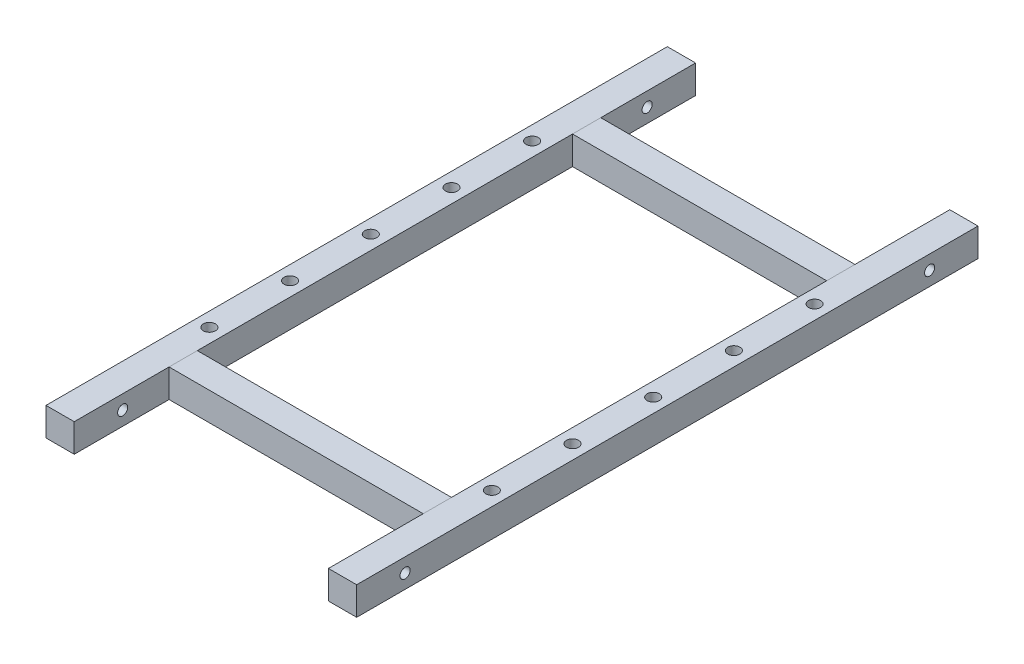
from build123d import *

# Parameters (mm, degrees)
SKETCH_14_W                   = 7
SKETCH_14_H                   = 7
BAR_7X7_1_DEPTH               = 154
SKETCH_14_ON_SEGMENT_2_W      = 7
SKETCH_14_ON_SEGMENT_2_H      = 7
BAR_7X7_1_2_DEPTH             = 154
SKETCH_14_ON_SEGMENT_3_W      = 7
SKETCH_14_ON_SEGMENT_3_H      = 7
BAR_7X7_1_3_DEPTH             = 72
SKETCH_14_ON_SEGMENT_4_W      = 7
SKETCH_14_ON_SEGMENT_4_H      = 7
BAR_7X7_1_4_DEPTH             = 72
SKETCH_12_R                   = 1.25
CUT_EXTRUDE_1_DEPTH           = 128.848543206
SKETCH_16_W                   = 1.5
SKETCH_16_H                   = 7
MM_TRANSITIONAL_1_AT_2_COUNT  = 2
MM_TRANSITIONAL_1_AT_2_PITCH  = 20
MM_TRANSITIONAL_1_AT_3_COUNT  = 2
MM_TRANSITIONAL_1_AT_3_PITCH  = 40
MM_TRANSITIONAL_1_AT_4_COUNT  = 2
MM_TRANSITIONAL_1_AT_4_PITCH  = 40
MM_TRANSITIONAL_1_AT_5_COUNT  = 2
MM_TRANSITIONAL_1_AT_5_PITCH  = 20
MM_TRANSITIONAL_1_AT_6_COUNT  = 2
MM_TRANSITIONAL_1_AT_6_PITCH  = 72.801098893
MM_TRANSITIONAL_1_AT_7_COUNT  = 2
MM_TRANSITIONAL_1_AT_7_PITCH  = 80.622577483
MM_TRANSITIONAL_1_AT_8_COUNT  = 2
MM_TRANSITIONAL_1_AT_8_PITCH  = 80.622577483
MM_TRANSITIONAL_1_AT_9_COUNT  = 2
MM_TRANSITIONAL_1_AT_9_PITCH  = 72.801098893
MM_TRANSITIONAL_1_AT_10_COUNT = 2
MM_TRANSITIONAL_1_AT_10_PITCH = 70


with BuildPart() as part:
    # 草图14 → Bar 7X7(1) (new body)
    with BuildSketch(Plane(origin=(-35, 0, -77), x_dir=(1, 0, 0), z_dir=(0, 0, 1))):
        Rectangle(SKETCH_14_W, SKETCH_14_H)
    extrude(amount=BAR_7X7_1_DEPTH)


with BuildPart() as body_2:
    # 草图14 on segment 2 (carried to segment 2) → Bar 7X7_1 2 (new body)
    with BuildSketch(Plane(origin=(35, 0, -77), x_dir=(1, 0, 0), z_dir=(0, 0, 1))):
        Rectangle(SKETCH_14_ON_SEGMENT_2_W, SKETCH_14_ON_SEGMENT_2_H)
    extrude(amount=BAR_7X7_1_2_DEPTH)


with BuildPart() as body_3:
    # 草图14 on segment 3 (carried to segment 3) → Bar 7X7_1 3 (new body)
    with BuildSketch(Plane(origin=(-36, 0, -50), x_dir=(0, 0, -1), z_dir=(1, 0, 0))):
        Rectangle(SKETCH_14_ON_SEGMENT_3_W, SKETCH_14_ON_SEGMENT_3_H)
    extrude(amount=BAR_7X7_1_3_DEPTH)

    # Bar 7X7_1 3 end butt 1
    split(bisect_by=Plane(origin=(-31.5, 0, -50), x_dir=(0, 1, 0), z_dir=(1, 0, 0)), keep=Keep.TOP)

    # Bar 7X7_1 3 end butt 2
    split(bisect_by=Plane(origin=(31.5, 0, -50), x_dir=(0, -1, 0), z_dir=(-1, 0, 0)), keep=Keep.TOP)


with BuildPart() as body_4:
    # 草图14 on segment 4 (carried to segment 4) → Bar 7X7_1 4 (new body)
    with BuildSketch(Plane(origin=(-36, 0, 50), x_dir=(0, 0, -1), z_dir=(1, 0, 0))):
        Rectangle(SKETCH_14_ON_SEGMENT_4_W, SKETCH_14_ON_SEGMENT_4_H)
    extrude(amount=BAR_7X7_1_4_DEPTH)

    # Bar 7X7_1 4 end butt 1
    split(bisect_by=Plane(origin=(-31.5, 0, 50), x_dir=(0, 1, 0), z_dir=(1, 0, 0)), keep=Keep.TOP)

    # Bar 7X7_1 4 end butt 2
    split(bisect_by=Plane(origin=(31.5, 0, 50), x_dir=(0, -1, 0), z_dir=(-1, 0, 0)), keep=Keep.TOP)


with BuildPart() as cut_extrude_1_tool:
    # 草图12 → 切除-拉伸1 (new, through all)
    with BuildSketch(Plane(origin=(-38.5, 0, 25), x_dir=(0, 0, -1), z_dir=(1, 0, 0))):
        with Locations((90, 0)):
            Circle(SKETCH_12_R)
    cut_extrude_1 = extrude(amount=CUT_EXTRUDE_1_DEPTH)


with BuildPart() as part_1:
    add(part.part)

    # 切除-拉伸1: cut by cut_extrude_1_tool
    add(cut_extrude_1_tool.part, mode=Mode.SUBTRACT)


with BuildPart() as body_2_1:
    add(body_2.part)

    # 切除-拉伸1: cut by cut_extrude_1_tool
    add(cut_extrude_1_tool.part, mode=Mode.SUBTRACT)


with BuildPart() as mirror_1_tool:
    # 镜向1: 切除-拉伸1 across plane
    add(cut_extrude_1.mirror(Plane.XY))


with BuildPart() as part_2:
    add(part_1.part)

    # 镜向1: cut by mirror_1_tool
    add(mirror_1_tool.part, mode=Mode.SUBTRACT)

    # 草图16 → 大小mm Transitional 暗销孔1 (revolve, cut)
    with BuildSketch(Plane(origin=(-35, 3.5, 0), x_dir=(0, 0, 1), z_dir=(1, 0, 0))):
        with Locations((0.75, 3.5)):
            Rectangle(SKETCH_16_W, SKETCH_16_H)
    mm_transitional_1 = revolve(axis=Axis((-35, 9.85, 0), (0, -1, 0)), mode=Mode.SUBTRACT)

    # 大小mm Transitional 暗销孔1 at 2: 大小mm Transitional 暗销孔1 ×2
    with Locations(*[(0, 0, -i * MM_TRANSITIONAL_1_AT_2_PITCH) for i in range(1, MM_TRANSITIONAL_1_AT_2_COUNT)]):
        add(mm_transitional_1, mode=Mode.SUBTRACT)

    # 大小mm Transitional 暗销孔1 at 3: 大小mm Transitional 暗销孔1 ×2
    with Locations(*[(0, 0, -i * MM_TRANSITIONAL_1_AT_3_PITCH) for i in range(1, MM_TRANSITIONAL_1_AT_3_COUNT)]):
        add(mm_transitional_1, mode=Mode.SUBTRACT)

    # 大小mm Transitional 暗销孔1 at 4: 大小mm Transitional 暗销孔1 ×2
    with Locations(*[(0, 0, i * MM_TRANSITIONAL_1_AT_4_PITCH) for i in range(1, MM_TRANSITIONAL_1_AT_4_COUNT)]):
        add(mm_transitional_1, mode=Mode.SUBTRACT)

    # 大小mm Transitional 暗销孔1 at 5: 大小mm Transitional 暗销孔1 ×2
    with Locations(*[(0, 0, i * MM_TRANSITIONAL_1_AT_5_PITCH) for i in range(1, MM_TRANSITIONAL_1_AT_5_COUNT)]):
        add(mm_transitional_1, mode=Mode.SUBTRACT)


with BuildPart() as body_2_2:
    add(body_2_1.part)

    # 镜向1: cut by mirror_1_tool
    add(mirror_1_tool.part, mode=Mode.SUBTRACT)

    # 大小mm Transitional 暗销孔1 at 6: 大小mm Transitional 暗销孔1 ×2
    with Locations(*[Vector(0.9615239476407995, 0, 0.27472112789746117) * (i * MM_TRANSITIONAL_1_AT_6_PITCH) for i in range(1, MM_TRANSITIONAL_1_AT_6_COUNT)]):
        add(mm_transitional_1, mode=Mode.SUBTRACT)

    # 大小mm Transitional 暗销孔1 at 7: 大小mm Transitional 暗销孔1 ×2
    with Locations(*[Vector(0.8682431421243894, 0, 0.4961389383569561) * (i * MM_TRANSITIONAL_1_AT_7_PITCH) for i in range(1, MM_TRANSITIONAL_1_AT_7_COUNT)]):
        add(mm_transitional_1, mode=Mode.SUBTRACT)

    # 大小mm Transitional 暗销孔1 at 8: 大小mm Transitional 暗销孔1 ×2
    with Locations(*[Vector(0.8682431421243892, 0, -0.49613893835695644) * (i * MM_TRANSITIONAL_1_AT_8_PITCH) for i in range(1, MM_TRANSITIONAL_1_AT_8_COUNT)]):
        add(mm_transitional_1, mode=Mode.SUBTRACT)

    # 大小mm Transitional 暗销孔1 at 9: 大小mm Transitional 暗销孔1 ×2
    with Locations(*[Vector(0.9615239476407993, 0, -0.27472112789746156) * (i * MM_TRANSITIONAL_1_AT_9_PITCH) for i in range(1, MM_TRANSITIONAL_1_AT_9_COUNT)]):
        add(mm_transitional_1, mode=Mode.SUBTRACT)

    # 大小mm Transitional 暗销孔1 at 10: 大小mm Transitional 暗销孔1 ×2
    with Locations(*[(i * MM_TRANSITIONAL_1_AT_10_PITCH, 0, 0) for i in range(1, MM_TRANSITIONAL_1_AT_10_COUNT)]):
        add(mm_transitional_1, mode=Mode.SUBTRACT)


solid = Compound([body_3.part, body_4.part, part_2.part, body_2_2.part])
